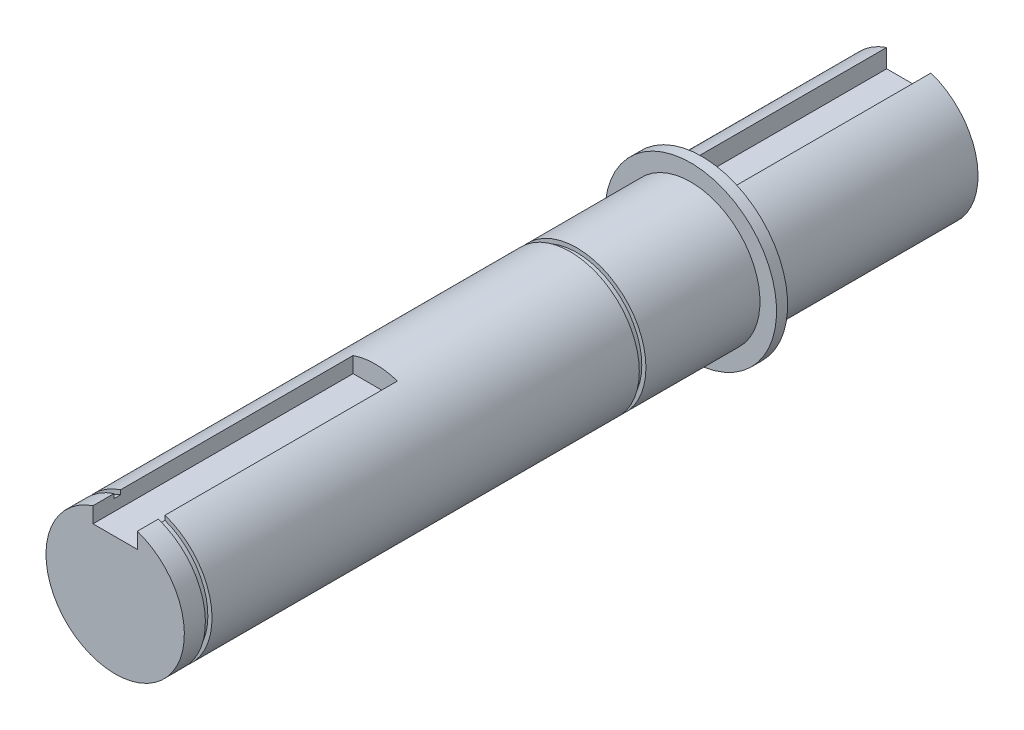
from build123d import *

# Parameters (mm, degrees)
SKETCH1_R           = 12.5
BOSS_EXTRUDE1_DEPTH = 143.4
SKETCH4_W           = 8
SKETCH4_H           = 8
CUT_EXTRUDE1_DEPTH  = 35.4
SKETCH11_R          = 15.5
BOSS_EXTRUDE4_DEPTH = 2
SKETCH12_R          = 12.5
SKETCH12_R_2        = 11.75
CUT_EXTRUDE2_DEPTH  = 1.2
SKETCH13_W          = 8
SKETCH13_H          = 7
CUT_EXTRUDE3_DEPTH  = 47
SKETCH16_R          = 12.5
SKETCH16_R_2        = 11.75
CUT_EXTRUDE5_DEPTH  = 1.2


with BuildPart() as part:
    # Sketch1 → Boss-Extrude1 (new body)
    with BuildSketch(Plane.XY):
        Circle(SKETCH1_R)
    extrude(amount=BOSS_EXTRUDE1_DEPTH)

    # Sketch4 → Cut-Extrude1 (cut)
    with BuildSketch(Plane(origin=(0, 0, 0), x_dir=(-1, 0, 0), z_dir=(0, 0, -1))):
        with Locations((0, 12.5)):
            Rectangle(SKETCH4_W, SKETCH4_H)
    extrude(amount=-CUT_EXTRUDE1_DEPTH, mode=Mode.SUBTRACT)

    # Sketch11 → Boss-Extrude4 (add)
    with BuildSketch(Plane(origin=(0, 0, 37.4), x_dir=(-1, 0, 0), z_dir=(0, 0, -1))):
        Circle(SKETCH11_R)
    extrude(amount=-BOSS_EXTRUDE4_DEPTH)

    # Sketch12 → Cut-Extrude2 (cut)
    with BuildSketch(Plane.XY.offset(60)):
        Circle(SKETCH12_R)
        Circle(SKETCH12_R_2, mode=Mode.SUBTRACT)
    extrude(amount=CUT_EXTRUDE2_DEPTH, mode=Mode.SUBTRACT)

    # Sketch13 → Cut-Extrude3 (cut)
    with BuildSketch(Plane.XY.offset(143.4)):
        with Locations((0, 12.5)):
            Rectangle(SKETCH13_W, SKETCH13_H)
    extrude(amount=-CUT_EXTRUDE3_DEPTH, mode=Mode.SUBTRACT)

    # Sketch16 → Cut-Extrude5 (cut)
    with BuildSketch(Plane.XY.offset(138.4)):
        Circle(SKETCH16_R)
        Circle(SKETCH16_R_2, mode=Mode.SUBTRACT)
    extrude(amount=CUT_EXTRUDE5_DEPTH, mode=Mode.SUBTRACT)


solid = part.part
